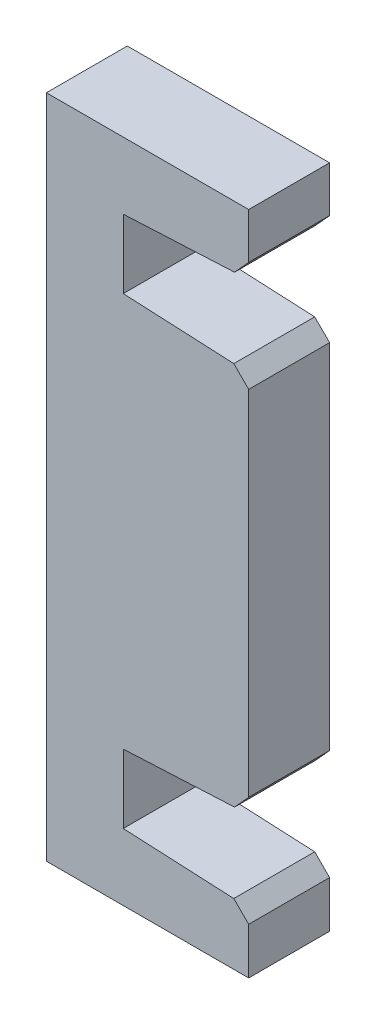
from build123d import *
from OCP.BRepFilletAPI import BRepFilletAPI_MakeChamfer

# Parameters (mm, degrees)
BOSS_EXTRUDE1_DEPTH = 4
CHAMFER1_SIZE       = 0.7
CHAMFER1_SIZE2      = 0.736453843


with BuildPart() as part:
    # Sketch1 → Boss-Extrude1 (new body)
    with BuildSketch(Plane.XY):
        Polygon((-10, 0), (0, 0), (0, 9.45), (-6.2, 9.75), (-6.2, 13.15), (0, 13.45), (0, 16.45), (-10, 16.45), align=None)
        Polygon((-6.2, -9.75), (0, -9.45), (0, 0), (-10, 0), (-10, -16.45), (0, -16.45), (0, -13.45), (-6.2, -13.15), align=None)
    extrude(amount=BOSS_EXTRUDE1_DEPTH)

    # Chamfer1: one chamfer whose edges measure the first distance from different faces: ONE call of the kernel's chamfer builder (chamfer() names one face for all edges)
    chamfer1_edges_1 = [part.edges().sort_by_distance(p)[0] for p in [
        (0, 13.45, 2),
    ]]
    chamfer1_side_1 = [part.faces().sort_by_distance(p)[0] for p in [
        (-3.1, 13.3, 2),
    ]]
    chamfer1_edges_2 = [part.edges().sort_by_distance(p)[0] for p in [
        (0, 9.45, 2),
    ]]
    chamfer1_side_2 = [part.faces().sort_by_distance(p)[0] for p in [
        (0, 0, 2),
    ]]
    chamfer1_edges_3 = [part.edges().sort_by_distance(p)[0] for p in [
        (0, -9.45, 2),
    ]]
    chamfer1_side_3 = [part.faces().sort_by_distance(p)[0] for p in [
        (-3.1, -9.6, 2),
    ]]
    chamfer1_edges_4 = [part.edges().sort_by_distance(p)[0] for p in [
        (0, -13.45, 2),
    ]]
    chamfer1_side_4 = [part.faces().sort_by_distance(p)[0] for p in [
        (0, -14.95, 2),
    ]]
    chamfer1 = BRepFilletAPI_MakeChamfer(part.part.solid().wrapped)
    for e in chamfer1_edges_1:
        chamfer1.Add(CHAMFER1_SIZE, CHAMFER1_SIZE2, e.wrapped, chamfer1_side_1[0].wrapped)  # the first distance lies on this face
    for e in chamfer1_edges_2:
        chamfer1.Add(CHAMFER1_SIZE, CHAMFER1_SIZE2, e.wrapped, chamfer1_side_2[0].wrapped)  # the first distance lies on this face
    for e in chamfer1_edges_3:
        chamfer1.Add(CHAMFER1_SIZE, CHAMFER1_SIZE2, e.wrapped, chamfer1_side_3[0].wrapped)  # the first distance lies on this face
    for e in chamfer1_edges_4:
        chamfer1.Add(CHAMFER1_SIZE, CHAMFER1_SIZE2, e.wrapped, chamfer1_side_4[0].wrapped)  # the first distance lies on this face
    add(Compound.cast(chamfer1.Shape()), mode=Mode.REPLACE)


solid = part.part
